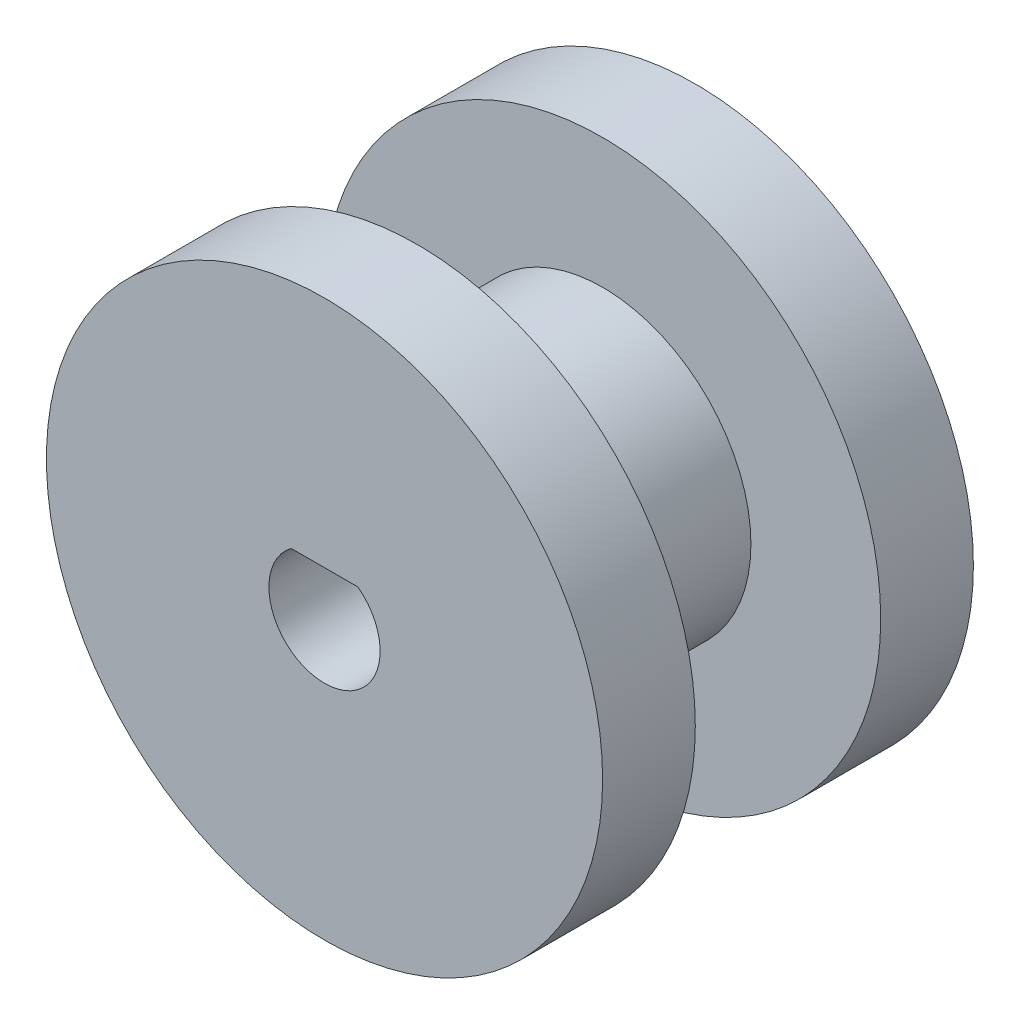
from build123d import *
from build123d.topology import SkipClean

# Parameters (mm, degrees)
ESQUISSE1_R        = 15
BOSS_EXTRU_2_DEPTH = 5
ESQUISSE3_R        = 8
ESQUISSE3_R_2      = 3
BOSS_EXTRU_3_DEPTH = 10
ESQUISSE4_R        = 15
ESQUISSE4_R_2      = 3
BOSS_EXTRU_4_DEPTH = 5
BOSS_EXTRU_5_DEPTH = 20


with BuildPart() as part:
    # Esquisse1 → Boss.-Extru.2 (new body)
    with BuildSketch(Plane.XY):
        Circle(ESQUISSE1_R)
        with BuildLine():
            ThreePointArc((3, 0), (-1.341640786, -2.683281573), (-1.8, 2.4))
            ThreePointArc((-1.8, 2.4), (0, 3), (1.8, 2.4))
            ThreePointArc((1.8, 2.4), (2.683281573, 1.341640786), (3, 0))
        make_face(mode=Mode.SUBTRACT)
    extrude(amount=BOSS_EXTRU_2_DEPTH)

    # Esquisse3 → Boss.-Extru.3 (add)
    with SkipClean():  # the faces are left unmerged after this step: merging them gives an invalid solid
        with BuildSketch(Plane.XY.offset(5)):
            Circle(ESQUISSE3_R)
            Circle(ESQUISSE3_R_2, mode=Mode.SUBTRACT)
        extrude(amount=BOSS_EXTRU_3_DEPTH)

    # Esquisse4 → Boss.-Extru.4 (add)
    with SkipClean():  # the faces are left unmerged after this step: merging them gives an invalid solid
        with BuildSketch(Plane.XY.offset(15)):
            Circle(ESQUISSE4_R)
            Circle(ESQUISSE4_R_2, mode=Mode.SUBTRACT)
        extrude(amount=BOSS_EXTRU_4_DEPTH)

    # Esquisse1_4 → Boss.-Extru.5 (add)
    with SkipClean():  # the faces are left unmerged after this step: merging them gives an invalid solid
        with BuildSketch(Plane.XY):
            with BuildLine():
                ThreePointArc((1.8, 2.4), (0, 3), (-1.8, 2.4))
                Line((-1.8, 2.4), (1.8, 2.4))
            make_face()
        extrude(amount=BOSS_EXTRU_5_DEPTH)


solid = part.part
